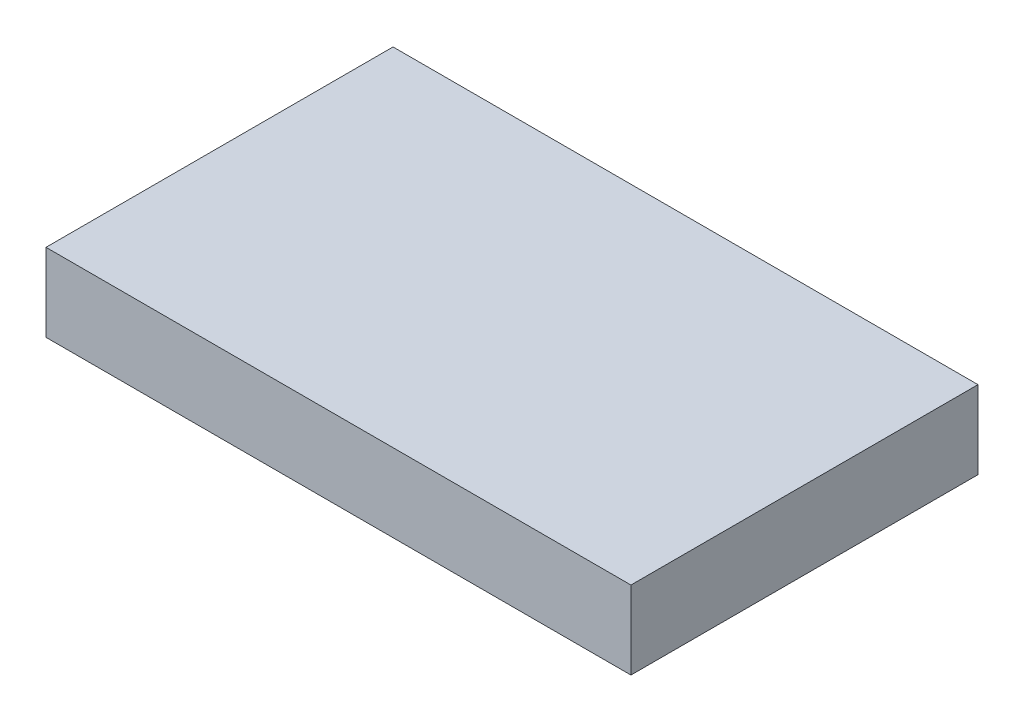
from build123d import *

# Parameters (mm, degrees)
SKETCH1_W           = 150
SKETCH1_H           = 89
BOSS_EXTRUDE1_DEPTH = 20


with BuildPart() as part:
    # Sketch1 → Boss-Extrude1 (new body)
    with BuildSketch(Plane(origin=(0, 0, 0), x_dir=(1, 0, 0), z_dir=(0, 1, 0))):
        with Locations((75, 44.5)):
            Rectangle(SKETCH1_W, SKETCH1_H)
    extrude(amount=BOSS_EXTRUDE1_DEPTH)


solid = part.part
